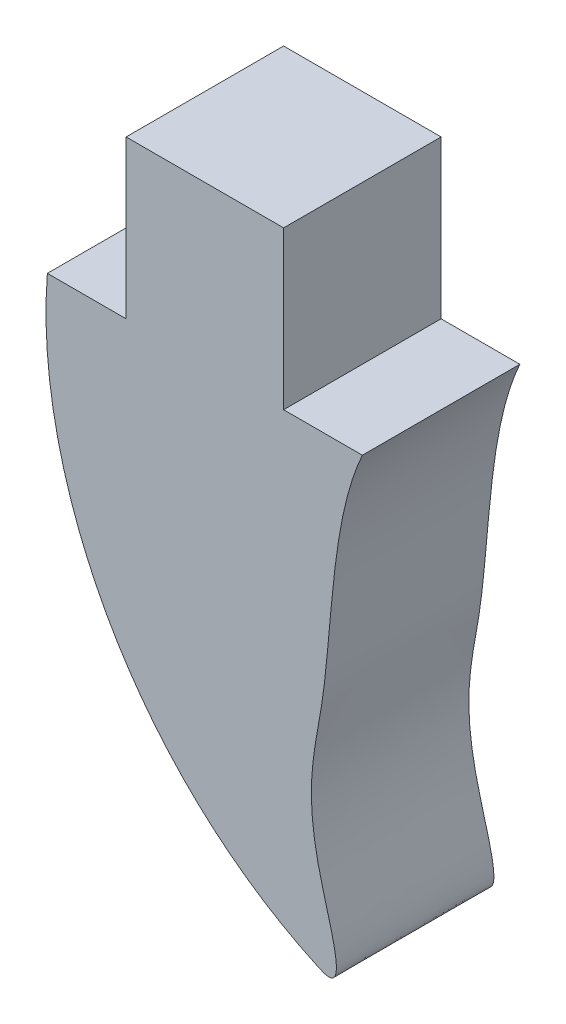
from build123d import *

# Parameters (mm, degrees)
SKETCH1_W           = 3.175
SKETCH1_H           = 3.175
BOSS_EXTRUDE1_DEPTH = 3.175


with BuildPart() as part:
    # Sketch1 → Boss-Extrude1 (new body)
    with BuildSketch(Plane.XY):
        with BuildLine():
            Line((-3.175, -1.5875), (3.175, -1.5875))
            add(Edge.make_bspline(
                [(-3.175, -1.5875), (-3.465873228, -5.278403535), (-1.364889429, -9.322338013), (2.937989627, -11.263457201), (1.845361549, -8.328568974), (2.607521985, -6.083334464), (2.531336319, -3.001419002), (3.175, -1.5875)],
                knots=[0, 0, 0, 0, 0.534256005, 0.543775636, 0.625264935, 0.768463685, 1, 1, 1, 1], degree=3))
        make_face()
        Rectangle(SKETCH1_W, SKETCH1_H)
    extrude(amount=BOSS_EXTRUDE1_DEPTH)


solid = part.part
